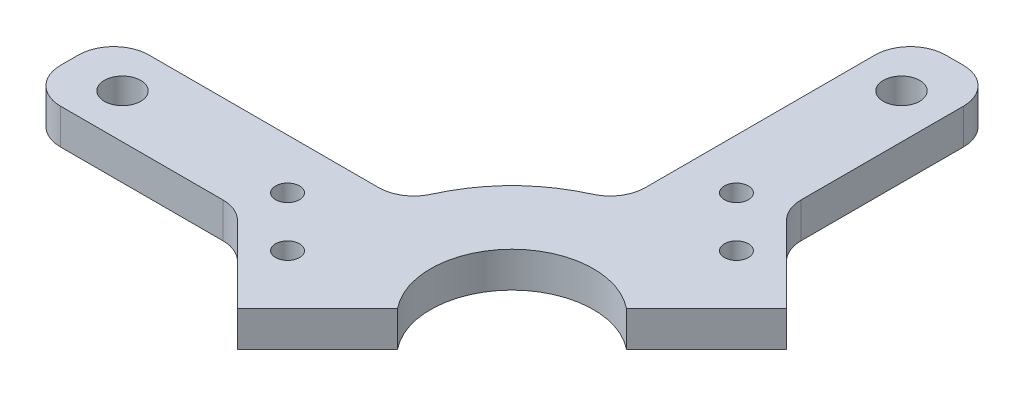
from build123d import *

# Parameters (mm, degrees)
SKETCH1_R                    = 28.575
SKETCH1_R_2                  = 14.605
BOSS_EXTRUDE1_DEPTH          = 6.35
BOSS_EXTRUDE2_DEPTH          = 6.35
F_0_257_DIAMETER_HOLE1_D     = 6.5278
CIRPATTERN1_COUNT            = 4
CUT_EXTRUDE1_DEPTH           = 113.432663181
FILLET1_R                    = 6.35
BOSS_EXTRUDE3_DEPTH          = 6.35
F_18_0_1695_DIAMETER_HOLE1_D = 4.3053
FILLET2_R                    = 6.35


with BuildPart() as part:
    # Sketch1 → Boss-Extrude1 (new body)
    with BuildSketch(Plane(origin=(0, 0, 0), x_dir=(1, 0, 0), z_dir=(0, 1, 0))):
        with Locations(Location((0, 0, 0), (0, 0, 270))):
            Circle(SKETCH1_R)
        with Locations(Location((0, 0, 0), (0, 0, 270))):
            Circle(SKETCH1_R_2, mode=Mode.SUBTRACT)
    extrude(amount=BOSS_EXTRUDE1_DEPTH)

    # Sketch2 → Boss-Extrude2 (add)
    with BuildSketch(Plane(origin=(0, 6.35, 0), x_dir=(1, 0, 0), z_dir=(0, 1, 0))):
        with BuildLine():
            Line((73.025, -7.9375), (25.4, -7.9375))
            Line((25.4, -7.9375), (25.4, 7.9375))
            Line((25.4, 7.9375), (73.025, 7.9375))
            ThreePointArc((73.025, 7.9375), (77.515128061, 6.077628061), (79.375, 1.5875))
            Line((79.375, 1.5875), (79.375, -1.5875))
            ThreePointArc((79.375, -1.5875), (77.515128061, -6.077628061), (73.025, -7.9375))
        make_face()
    boss_extrude2 = extrude(amount=-BOSS_EXTRUDE2_DEPTH)

    # F (0.257) Diameter Hole1 (through all)
    with Locations(Plane(origin=(0, 6.35, 0), x_dir=(1, 0, 0), z_dir=(0, 1, 0))):
        with Locations((69.85, 0)):
            f_0_257_diameter_hole1 = Hole(F_0_257_DIAMETER_HOLE1_D / 2)

    # CirPattern1: Boss-Extrude2, F (0.257) Diameter Hole1 ×4 about axis
    cirpattern1_axis = Axis((0, 0, 0), (0, 1, 0))
    add([boss_extrude2.rotate(cirpattern1_axis, i * 360 / CIRPATTERN1_COUNT) for i in range(1, CIRPATTERN1_COUNT)])
    add([f_0_257_diameter_hole1.rotate(cirpattern1_axis, i * 360 / CIRPATTERN1_COUNT) for i in range(1, CIRPATTERN1_COUNT)], mode=Mode.SUBTRACT)

    # Sketch5 → Cut-Extrude1 (cut, through all)
    with BuildSketch(Plane(origin=(0, 6.35, 0), x_dir=(1, 0, 0), z_dir=(0, 1, 0))):
        Polygon((-38.294182992, -36.049118961), (36.049118961, 38.294182992), (38.294182992, 36.049118961), (-36.049118961, -38.294182992), align=None)
    extrude(amount=-CUT_EXTRUDE1_DEPTH, mode=Mode.SUBTRACT)


with BuildPart() as body_2:
    # of the pieces the cut leaves, the one that is kept (cut_extrude1_keep)
    add(part.part.solids().sort_by_distance((19.051838715, 0, -21.296902746))[0])

    # Fillet1
    fillet1_edges = [body_2.edges().sort_by_distance(p)[0] for p in [
        (-7.9375, 3.175, -27.450441139),
        (-27.450441139, 3.175, -7.9375),
    ]]
    fillet(fillet1_edges, radius=FILLET1_R)

    # Sketch7 → Boss-Extrude3 (add)
    with BuildSketch(Plane(origin=(0, 6.35, 0), x_dir=(1, 0, 0), z_dir=(0, 1, 0))):
        Polygon((-14.513140303, -12.268076272), (-25.738460454, -23.493396424), (-45.944036726, -3.287820151), (-34.718716575, 7.9375), align=None)
    boss_extrude3 = extrude(amount=-BOSS_EXTRUDE3_DEPTH)

    # #18 (0.1695) Diameter Hole1 (through all)
    with Locations(Plane(origin=(0, 6.35, 0), x_dir=(1, 0, 0), z_dir=(0, 1, 0))):
        with Locations((-30.228588515, -10.023012242), (-39.208844636, -1.042756121)):
            f_18_0_1695_diameter_hole1 = Hole(F_18_0_1695_DIAMETER_HOLE1_D / 2)

    # Mirror1: Boss-Extrude3, #18 (0.1695) Diameter Hole1 across plane
    add(boss_extrude3.mirror(Plane(origin=(0, 0, 0), x_dir=(0.7071067811865478, 0, 0.7071067811865472), z_dir=(0.7071067811865475, 0, -0.7071067811865477))))
    add(f_18_0_1695_diameter_hole1.mirror(Plane(origin=(0, 0, 0), x_dir=(0.7071067811865478, 0, 0.7071067811865472), z_dir=(0.7071067811865475, 0, -0.7071067811865477))), mode=Mode.SUBTRACT)

    # Fillet2
    fillet2_edges = [body_2.edges().sort_by_distance(p)[0] for p in [
        (-41.294356878, 3.175, 7.9375),
        (7.9375, 3.175, -41.294356878),
    ]]
    fillet(fillet2_edges, radius=FILLET2_R)


solid = body_2.part
